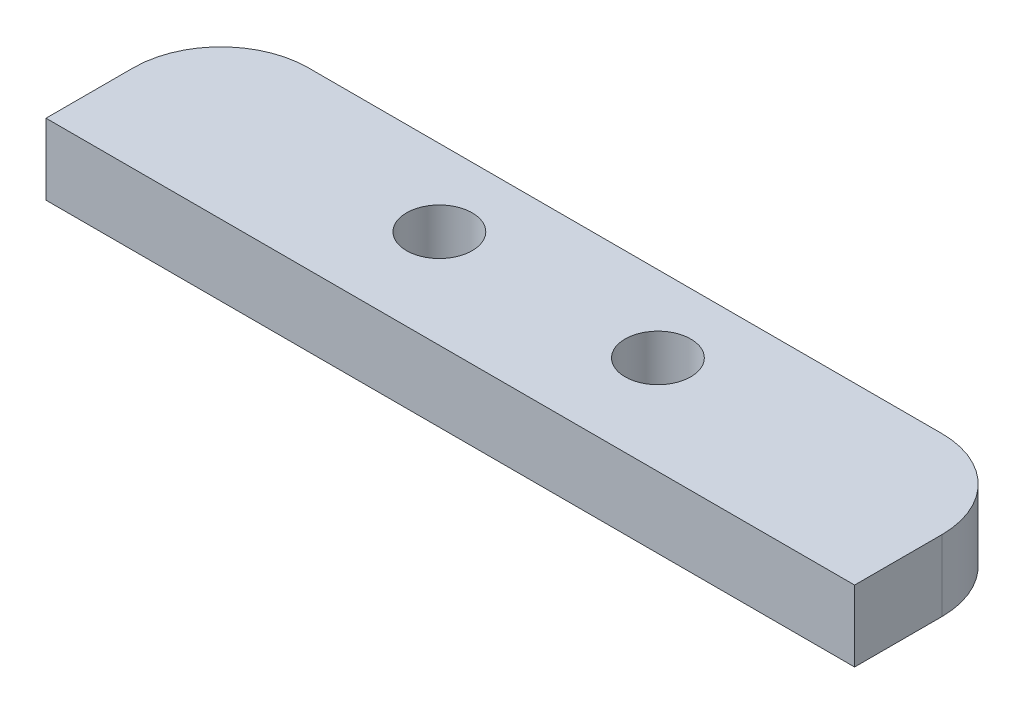
from build123d import *

# Parameters (mm, degrees)
SKETCH1_R           = 1.5025
BOSS_EXTRUDE1_DEPTH = 3.25


with BuildPart() as part:
    # Sketch1 → Boss-Extrude1 (new body)
    with BuildSketch(Plane(origin=(0, 0, 0), x_dir=(1, 0, 0), z_dir=(0, 1, 0))):
        with BuildLine():
            Line((-14.5, 4), (14.5, 4))
            ThreePointArc((14.5, 4), (17.328427125, 2.828427125), (18.5, 0))
            Line((18.5, 0), (18.5, -4))
            Line((18.5, -4), (-18.5, -4))
            Line((-18.5, -4), (-18.5, 0))
            ThreePointArc((-18.5, 0), (-17.328427125, 2.828427125), (-14.5, 4))
        make_face()
        with Locations((-5, 0.5)):
            Circle(SKETCH1_R, mode=Mode.SUBTRACT)
        with Locations((5, 0.5)):
            Circle(SKETCH1_R, mode=Mode.SUBTRACT)
    extrude(amount=BOSS_EXTRUDE1_DEPTH)


solid = part.part
